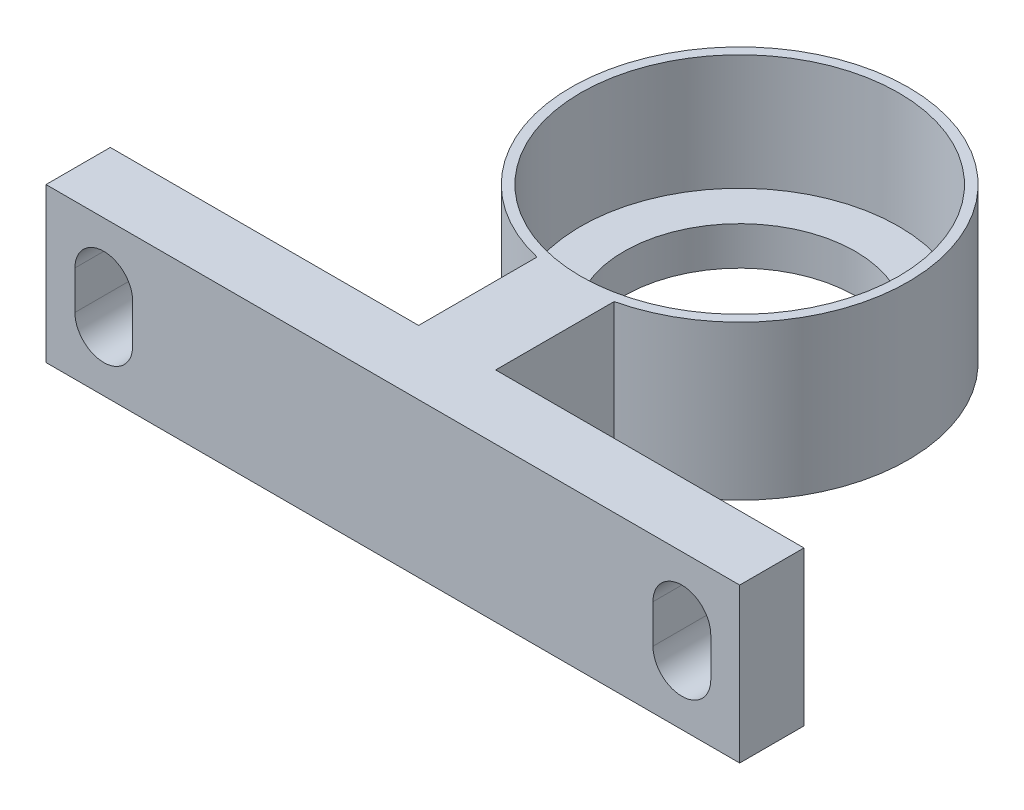
from build123d import *

# Parameters (mm, degrees)
SKETCH_1_R          = 8.75
SKETCH_1_R_2        = 8.25
EXTRUDE_2_DEPTH     = 10
SKETCH_2_R          = 8.25
SKETCH_2_R_2        = 2
EXTRUDE_3_DEPTH     = 4
EXTRUDE_4_DEPTH     = 8
SKETCH_5_W          = 3
SKETCH_5_H          = 8
EXTRUDE_5_DEPTH     = 3
SKETCH_6_W          = 3
SKETCH_6_H          = 8
EXTRUDE_6_DEPTH     = 3
SKETCH_7_R          = 1.5
CUT_EXTRUDE_1_DEPTH = 3
FILLET_1_R          = 5
FILLET_3_R          = 2
SKETCH_8_R          = 8.75
SKETCH_8_R_2        = 8.25
EXTRUDE_7_DEPTH     = 8
SKETCH_9_R          = 8.25
SKETCH_9_R_2        = 6
EXTRUDE_8_DEPTH     = 2
EXTRUDE_9_DEPTH     = 8
SKETCH_11_R         = 1.5
CUT_EXTRUDE_2_DEPTH = 8
CUT_EXTRUDE_3_DEPTH = 8
CUT_EXTRUDE_4_DEPTH = 8
SKETCH_14_R         = 8.75
SKETCH_14_R_2       = 8.25
EXTRUDE_10_DEPTH    = 8
EXTRUDE_11_DEPTH    = 8
SKETCH_16_R         = 1.5
CUT_EXTRUDE_5_DEPTH = 8
CUT_EXTRUDE_6_DEPTH = 10
CUT_EXTRUDE_7_DEPTH = 10


with BuildPart() as part:
    # 草图1 → 凸台-拉伸2 (new body)
    with BuildSketch(Plane(origin=(0, 0, 0), x_dir=(1, 0, 0), z_dir=(0, 1, 0))):
        Circle(SKETCH_1_R)
        Circle(SKETCH_1_R_2, mode=Mode.SUBTRACT)
    extrude(amount=EXTRUDE_2_DEPTH)

    # 草图2 → 凸台-拉伸3 (add)
    with BuildSketch(Plane(origin=(0, 0, 0), x_dir=(1, 0, 0), z_dir=(0, 1, 0))):
        Circle(SKETCH_2_R)
        Circle(SKETCH_2_R_2, mode=Mode.SUBTRACT)
    extrude(amount=EXTRUDE_3_DEPTH)

    # 草图3 → 凸台-拉伸4 (add)
    with BuildSketch(Plane(origin=(0, 0, 0), x_dir=(1, 0, 0), z_dir=(0, 1, 0))):
        Polygon((-2, 8.518362519), (2, 8.518362519), (2, 15), (15, 15), (15, 18), (2, 18), (-2, 18), (-15, 18), (-15, 15), (-2, 15), align=None)
    extrude(amount=EXTRUDE_4_DEPTH)

    # 草图5 → 凸台-拉伸5 (add)
    with BuildSketch(Plane(origin=(15, 0, 0), x_dir=(0, 0, -1), z_dir=(1, 0, 0))):
        with Locations((16.5, 4)):
            Rectangle(SKETCH_5_W, SKETCH_5_H)
    extrude(amount=EXTRUDE_5_DEPTH)

    # 草图6 → 凸台-拉伸6 (add)
    with BuildSketch(Plane.ZY.offset(15)):
        with Locations((-16.5, 4)):
            Rectangle(SKETCH_6_W, SKETCH_6_H)
    extrude(amount=EXTRUDE_6_DEPTH)

    # 草图7 → 切除-拉伸1 (cut)
    with BuildSketch(Plane(origin=(0, 0, -18), x_dir=(-1, 0, 0), z_dir=(0, 0, -1))):
        with Locations((-15, 3.754021035)):
            Circle(SKETCH_7_R)
    cut_extrude_1 = extrude(amount=-CUT_EXTRUDE_1_DEPTH, mode=Mode.SUBTRACT)

    # 镜向1: 切除-拉伸1 across plane
    add(cut_extrude_1.mirror(Plane(origin=(0, 0, 0), x_dir=(0, 0, 1), z_dir=(1, 0, 0))), mode=Mode.SUBTRACT)

    # 圆角1
    fillet_1_edges = [part.edges().sort_by_distance(p)[0] for p in [
        (-2, 4, -8.518362519),
        (2, 4, -8.518362519),
    ]]
    fillet(fillet_1_edges, radius=FILLET_1_R)

    # 圆角3
    fillet_3_edges = [part.edges().sort_by_distance(p)[0] for p in [
        (-2, 4, -15),
        (2, 4, -15),
    ]]
    fillet(fillet_3_edges, radius=FILLET_3_R)

    # 草图17 → 切除-拉伸6 (cut)
    with BuildSketch(Plane(origin=(0, 0, 0), x_dir=(1, 0, 0), z_dir=(0, 1, 0))):
        Polygon((-27.724622817, 21.69601187), (-7.349237756, -14.338233932), (7.177657148, -11.696980313), (13.592130223, 5.659829184), (24.157144699, 16.036182687), (2.467165325, 27.553795746), (0, 27.553795746), align=None)
    extrude(amount=CUT_EXTRUDE_6_DEPTH, mode=Mode.SUBTRACT)


with BuildPart() as body_2:
    # 草图8 → 凸台-拉伸7 (new body)
    with BuildSketch(Plane(origin=(0, 0, 0), x_dir=(1, 0, 0), z_dir=(0, 1, 0))):
        with Locations((27.184954533, 0)):
            Circle(SKETCH_8_R)
        with Locations((27.184954533, 0)):
            Circle(SKETCH_8_R_2, mode=Mode.SUBTRACT)
    extrude(amount=EXTRUDE_7_DEPTH)

    # 草图9 → 凸台-拉伸8 (add)
    with BuildSketch(Plane.XZ):
        with Locations((27.184954533, 0)):
            Circle(SKETCH_9_R)
        with Locations((27.184954533, 0)):
            Circle(SKETCH_9_R_2, mode=Mode.SUBTRACT)
    extrude(amount=-EXTRUDE_8_DEPTH)

    # 草图10 → 凸台-拉伸9 (add)
    with BuildSketch(Plane(origin=(0, 0, 0), x_dir=(1, 0, 0), z_dir=(0, 1, 0))):
        Polygon((27.184954533, -18), (45.184954533, -18), (45.184954533, -14.663867829), (29.184954533, -14.663867829), (29.184954533, -8.518362519), (25.184954533, -8.518362519), (25.184954533, -14.663867829), (9.184954533, -14.663867829), (9.184954533, -18), align=None)
    extrude(amount=EXTRUDE_9_DEPTH)

    # 草图11 → 切除-拉伸2 (cut)
    with BuildSketch(Plane.XY.offset(18)):
        with Locations((12.184954533, 4)):
            Circle(SKETCH_11_R)
        with Locations((42.184954533, 4)):
            Circle(SKETCH_11_R)
    extrude(amount=-CUT_EXTRUDE_2_DEPTH, mode=Mode.SUBTRACT)

    # 草图12 → 切除-拉伸3 (cut)
    with BuildSketch(Plane.XY.offset(18)):
        with BuildLine():
            Line((10.684954533, 4), (10.684954533, 5))
            ThreePointArc((10.684954533, 5), (12.184954533, 6.5), (13.684954533, 5))
            Line((13.684954533, 5), (13.684954533, 4))
            Line((13.684954533, 4), (13.684954533, 3))
            ThreePointArc((13.684954533, 3), (12.184954533, 1.5), (10.684954533, 3))
            Line((10.684954533, 3), (10.684954533, 4))
        make_face()
    extrude(amount=-CUT_EXTRUDE_3_DEPTH, mode=Mode.SUBTRACT)

    # 草图13 → 切除-拉伸4 (cut)
    with BuildSketch(Plane.XY.offset(18)):
        with BuildLine():
            Line((40.684954533, 4), (40.684954533, 5))
            ThreePointArc((40.684954533, 5), (42.184954533, 6.5), (43.684954533, 5))
            Line((43.684954533, 5), (43.684954533, 4))
            Line((43.684954533, 4), (43.684954533, 3))
            ThreePointArc((43.684954533, 3), (42.184954533, 1.5), (40.684954533, 3))
            Line((40.684954533, 3), (40.684954533, 4))
        make_face()
    extrude(amount=-CUT_EXTRUDE_4_DEPTH, mode=Mode.SUBTRACT)


with BuildPart() as body_3:
    # 草图14 → 凸台-拉伸10 (new body)
    with BuildSketch(Plane(origin=(0, 0, 0), x_dir=(1, 0, 0), z_dir=(0, 1, 0))):
        with Locations((-35.091635024, 0)):
            Circle(SKETCH_14_R)
        with Locations((-35.091635024, 0)):
            Circle(SKETCH_14_R_2, mode=Mode.SUBTRACT)
    extrude(amount=EXTRUDE_10_DEPTH)

    # 草图15 → 凸台-拉伸11 (add)
    with BuildSketch(Plane(origin=(0, 0, 0), x_dir=(1, 0, 0), z_dir=(0, 1, 0))):
        Polygon((-37.091635024, -15), (-37.091635024, -8.518362519), (-33.091635024, -8.518362519), (-33.091635024, -15), (-17.091635024, -15), (-17.091635024, -18), (-53.091635024, -18), (-53.091635024, -15), align=None)
    extrude(amount=EXTRUDE_11_DEPTH)

    # 草图16 → 切除-拉伸5 (cut)
    with BuildSketch(Plane.XY.offset(18)):
        with Locations((-50.091635024, 4)):
            Circle(SKETCH_16_R)
        with Locations((-20.091635024, 4)):
            Circle(SKETCH_16_R)
    extrude(amount=-CUT_EXTRUDE_5_DEPTH, mode=Mode.SUBTRACT)

    # 草图18 → 切除-拉伸7 (cut)
    with BuildSketch(Plane(origin=(0, 0, 0), x_dir=(1, 0, 0), z_dir=(0, 1, 0))):
        Polygon((-5.334341173, 26.542566247), (-7.107938045, -29.653340051), (-79.00930818, -22.653952159), (-79.00930818, -19.085416228), (-48.199741002, 26.542566247), align=None)
    extrude(amount=CUT_EXTRUDE_7_DEPTH, mode=Mode.SUBTRACT)


solid = body_2.part
